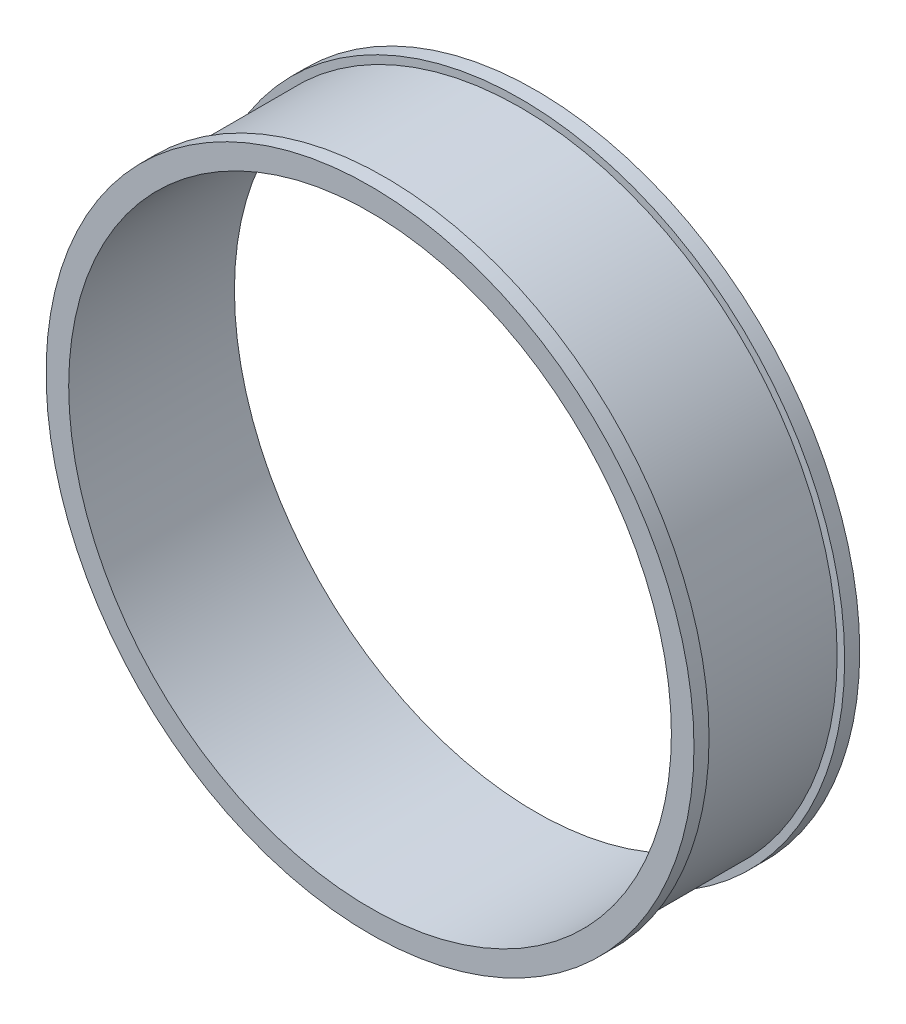
from build123d import *


with BuildPart() as part:
    # Sketch2 → Revolve1 (revolve)
    with BuildSketch(Plane(origin=(0, 0, 0), x_dir=(1, 0, 0), z_dir=(0, 1, 0))):
        Polygon((-210, 45), (-215, 45), (-215, 55), (-200, 55), (-200, -55), (-215, -55), (-215, -45), (-210, -45), align=None)
    revolve(axis=Axis((0, 0, 131.756950561), (0, 0, -1)))


solid = part.part
